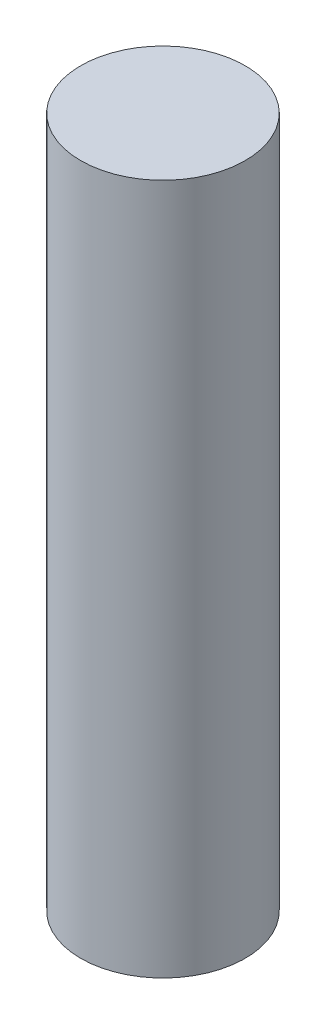
from build123d import *

# Parameters (mm, degrees)
SKETCH1_R           = 7.5
BOSS_EXTRUDE1_DEPTH = 63


with BuildPart() as part:
    # Sketch1 → Boss-Extrude1 (new body)
    with BuildSketch(Plane(origin=(0, 0, 0), x_dir=(1, 0, 0), z_dir=(0, 1, 0))):
        Circle(SKETCH1_R)
    extrude(amount=BOSS_EXTRUDE1_DEPTH)


solid = part.part
